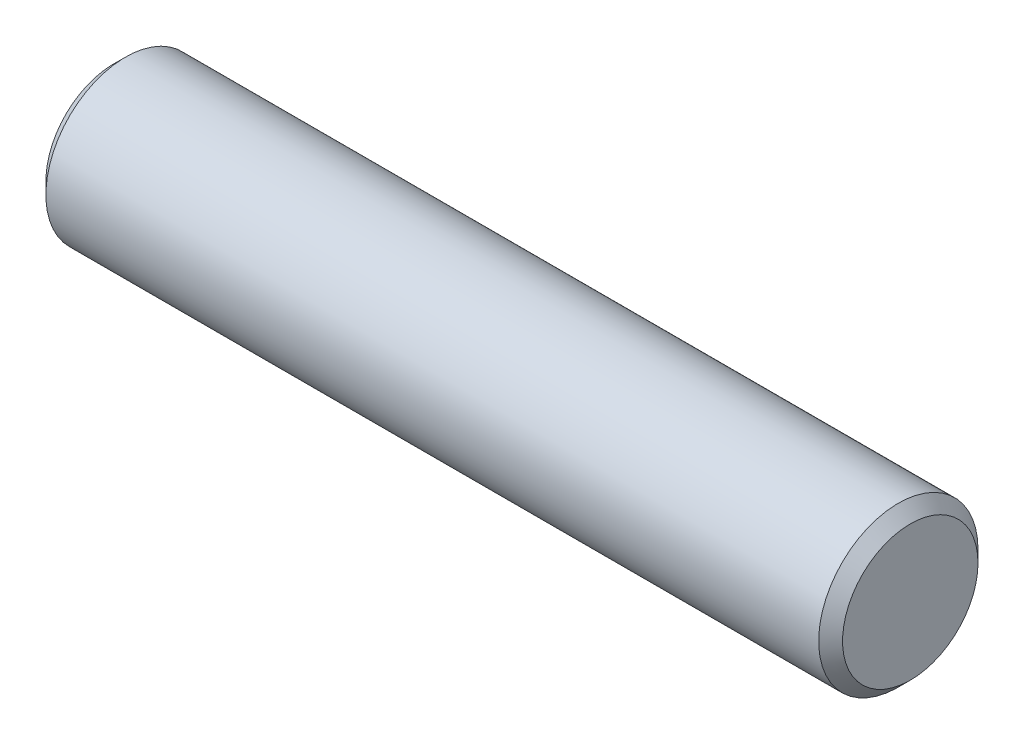
from build123d import *

# Parameters (mm, degrees)
BODYSKE_W     = 100
BODYSKE_H     = 10
CHAMFER1_SIZE = 1.5


with BuildPart() as part:
    # BodySke → BaseBody (revolve)
    with BuildSketch(Plane.XY):
        with Locations((50, 5)):
            Rectangle(BODYSKE_W, BODYSKE_H)
    revolve(axis=Axis((-3.175, 0, 0), (1, 0, 0)))

    # Chamfer1
    chamfer1_edges = [part.edges().sort_by_distance(p)[0] for p in [
        (100, -10, 0),
        (0, -10, 0),
    ]]
    chamfer(chamfer1_edges, length=CHAMFER1_SIZE)


solid = part.part
